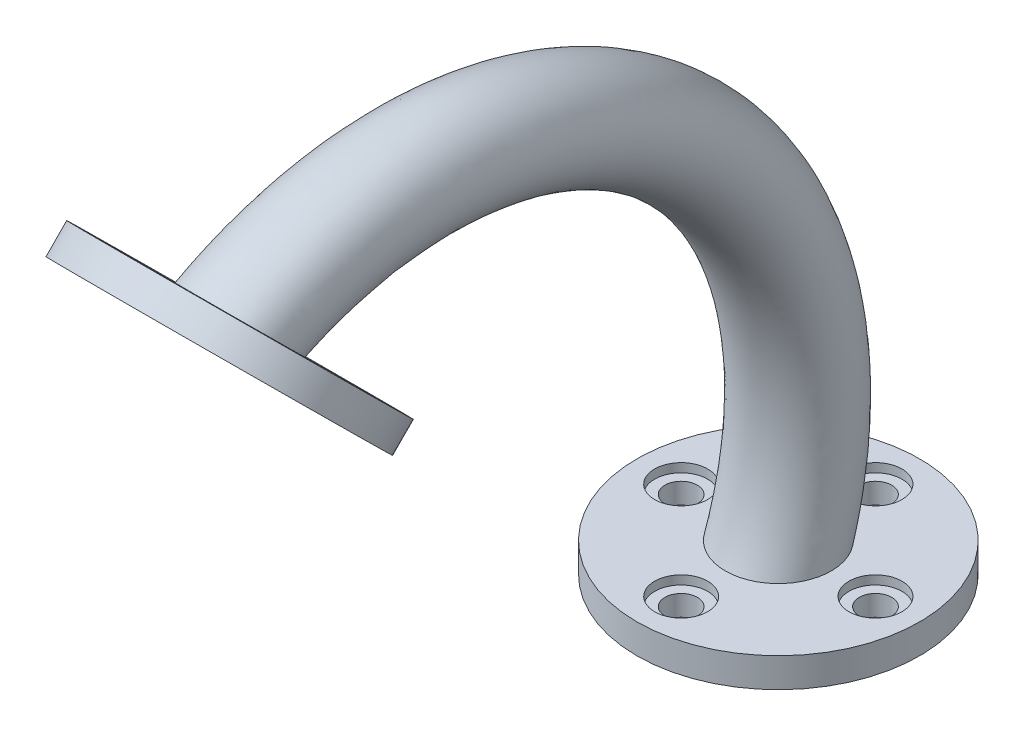
from build123d import *

# Parameters (mm, degrees)
CROQUIS1_R              = 48
CROQUIS1_R_2            = 13.5
SALIENTE_EXTRUIR3_DEPTH = 10
TALADRO1_D              = 11
TALADRO1_DEPTH          = 100
TALADRO1_CBORE_D        = 18
TALADRO1_CBORE_DEPTH    = 3
TALADRO1_TIP            = 3.304733405
CROQUIS9_R              = 18
CROQUIS9_R_2            = 13.5
CROQUIS15_R             = 48
CROQUIS15_R_2           = 13.5
SALIENTE_EXTRUIR5_DEPTH = 10
TALADRO3_AT_2_COUNT     = 2
TALADRO3_AT_2_PITCH     = 42.426406871
TALADRO3_AT_3_COUNT     = 2
TALADRO3_AT_3_PITCH     = 60
TALADRO3_AT_4_COUNT     = 2
TALADRO3_AT_4_PITCH     = 42.426406871


with BuildPart() as part:
    # Croquis1 → Saliente-Extruir3 (new body)
    with BuildSketch(Plane(origin=(0, 0, 0), x_dir=(1, 0, 0), z_dir=(0, 1, 0))):
        Circle(CROQUIS1_R)
        Circle(CROQUIS1_R_2, mode=Mode.SUBTRACT)
    extrude(amount=SALIENTE_EXTRUIR3_DEPTH)

    # Taladro1
    with Locations(Plane(origin=(0, 10, 0), x_dir=(1, 0, 0), z_dir=(0, 1, 0))):
        with Locations((-33, 0), (0, 33), (33, 0), (0, -33)):
            CounterBoreHole(TALADRO1_D / 2, TALADRO1_CBORE_D / 2, TALADRO1_CBORE_DEPTH, depth=TALADRO1_DEPTH)
            with Locations((0, 0, -(TALADRO1_DEPTH + TALADRO1_TIP / 2))):  # 118° drill point
                Cone(0, TALADRO1_D / 2, TALADRO1_TIP, mode=Mode.SUBTRACT)

    # Barrer2: sweep along a path in Croquis14
    with BuildLine(Plane(origin=(0, 0, 0), x_dir=(0, 0, -1), z_dir=(1, 0, 0))) as barrer2_path:
        ThreePointArc((0, 10), (-39.065769178, 149.354207944), (-182.805987365, 166.220721172))
    # Croquis9 → Barrer2 (sweep)
    with BuildSketch(Plane(origin=(0, 10, 0), x_dir=(1, 0, 0), z_dir=(0, 1, 0))):
        Circle(CROQUIS9_R)
        Circle(CROQUIS9_R_2, mode=Mode.SUBTRACT)
    sweep(path=barrer2_path.line)

    # Croquis15 → Saliente-Extruir5 (add)
    with BuildSketch(Plane(origin=(0, -7.432010892, 7.35587441), x_dir=(1, 0, 0), z_dir=(0, -0.710737951, 0.703456868))):
        with Locations((0, 246.856260786)):
            Circle(CROQUIS15_R)
        with Locations((0, 246.856260786)):
            Circle(CROQUIS15_R_2, mode=Mode.SUBTRACT)
    extrude(amount=SALIENTE_EXTRUIR5_DEPTH)

    # Croquis21 → Taladro3 (revolve, cut)
    with BuildSketch(Plane(origin=(30, 168.331091776, 184.938201218), x_dir=(0, 0.703456868, 0.710737951), z_dir=(1, 0, 0))):
        Polygon((0, 0), (0, 103.304733405), (5.5, 100), (5.5, 3), (9, 3), (9, 0), align=None)
    taladro3 = revolve(axis=Axis((30, 176.370159924, 176.981488488), (0, -0.710737951, 0.703456868)), mode=Mode.SUBTRACT)

    # Taladro3 at 2: Taladro3 ×2
    with Locations(*[Vector(-0.707106781, 0.497419122, 0.502567625) * (i * TALADRO3_AT_2_PITCH) for i in range(1, TALADRO3_AT_2_COUNT)]):
        add(taladro3, mode=Mode.SUBTRACT)

    # Taladro3 at 3: Taladro3 ×2
    with Locations(*[(-i * TALADRO3_AT_3_PITCH, 0, 0) for i in range(1, TALADRO3_AT_3_COUNT)]):
        add(taladro3, mode=Mode.SUBTRACT)

    # Taladro3 at 4: Taladro3 ×2
    with Locations(*[Vector(-0.707106781, -0.497419122, -0.502567625) * (i * TALADRO3_AT_4_PITCH) for i in range(1, TALADRO3_AT_4_COUNT)]):
        add(taladro3, mode=Mode.SUBTRACT)


solid = part.part
